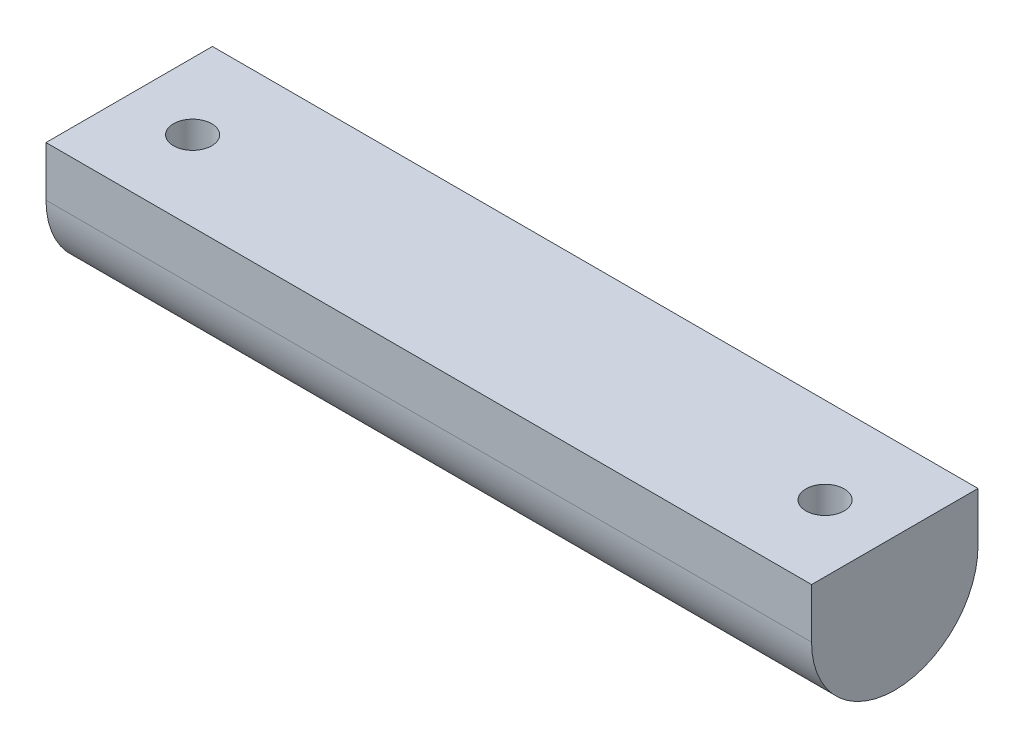
from build123d import *

# Parameters (mm, degrees)
BOSS_EXTRUDE1_DEPTH          = 230
F_11_5_11_5_DIAMETER_HOLE2_D = 11.5


with BuildPart() as part:
    # Sketch1 → Boss-Extrude1 (new body)
    with BuildSketch(Plane(origin=(0, 0, 0), x_dir=(0, 0, -1), z_dir=(1, 0, 0))):
        with BuildLine():
            Line((-24.046920821, 0), (-24.046920821, 15))
            Line((-24.046920821, 15), (25.953079179, 15))
            Line((25.953079179, 15), (25.953079179, 0))
            ThreePointArc((25.953079179, 0), (0.953079179, -25), (-24.046920821, 0))
        make_face()
    extrude(amount=BOSS_EXTRUDE1_DEPTH)

    # Ø11.5 (11.5) Diameter Hole2 (through all)
    with Locations(Plane(origin=(0, 15, 0), x_dir=(1, 0, 0), z_dir=(0, 1, 0))):
        with Locations((20, 0), (210, 0)):
            Hole(F_11_5_11_5_DIAMETER_HOLE2_D / 2)


solid = part.part
